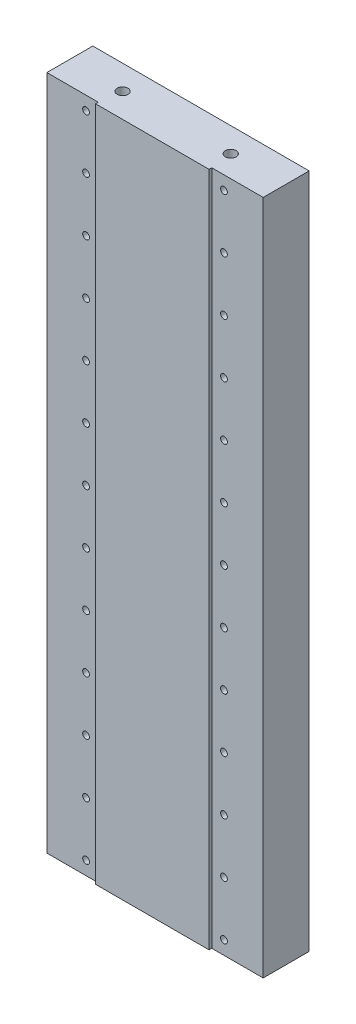
from build123d import *

# Parameters (mm, degrees)
CROQUIS1_W                         = 80
CROQUIS1_H                         = 250
SALIENTE_EXTRUIR1_DEPTH            = 18
CROQUIS2_W                         = 19
CROQUIS2_H                         = 250
CORTAR_EXTRUIR1_DEPTH              = 1
MATRIZL1_COUNT                     = 13
MATRIZL1_PITCH                     = 20
MATRIZL1_COUNT_DIR2                = 2
MATRIZL1_PITCH_DIR2                = 51
TALADROS_DE_ESPIGA_DE_4_0MM1_D     = 4
TALADROS_DE_ESPIGA_DE_4_0MM1_DEPTH = 12
TALADROS_DE_ESPIGA_DE_4_0MM1_TIP   = 1.201721238
TALADRO_ROSCADO_M41_D              = 3.3
TALADRO_ROSCADO_M41_DEPTH          = 11.5
TALADRO_ROSCADO_M41_TIP            = 0.991420021


with BuildPart() as part:
    # Croquis1 → Saliente-Extruir1 (new body)
    with BuildSketch(Plane.XY):
        with Locations((40, 125)):
            Rectangle(CROQUIS1_W, CROQUIS1_H)
    extrude(amount=SALIENTE_EXTRUIR1_DEPTH)

    # Croquis2 → Cortar-Extruir1 (cut)
    with BuildSketch(Plane.XY.offset(18)):
        with Locations((9.5, 125)):
            Rectangle(CROQUIS2_W, CROQUIS2_H)
        with Locations((70.5, 125)):
            Rectangle(CROQUIS2_W, CROQUIS2_H)
    extrude(amount=-CORTAR_EXTRUIR1_DEPTH, mode=Mode.SUBTRACT)

    # Croquis4 → Taladro roscado M31 (revolve, cut)
    with BuildSketch(Plane(origin=(14.5, 245, 17), x_dir=(0, -1, 0), z_dir=(1, 0, 0))):
        Polygon((0, 0), (0, 10.751075774), (1.25, 10), (1.25, 0), align=None)
    taladro_roscado_m31 = revolve(axis=Axis((14.5, 245, 23.35), (0, 0, -1)), mode=Mode.SUBTRACT)

    # MatrizL1: Taladro roscado M31 13 × 2
    with Locations(*[(j * MATRIZL1_PITCH_DIR2, -i * MATRIZL1_PITCH, 0) for i in range(MATRIZL1_COUNT) for j in range(MATRIZL1_COUNT_DIR2) if (i, j) != (0, 0)]):
        add(taladro_roscado_m31, mode=Mode.SUBTRACT)

    # Taladros de espiga de Ø4.0mm1
    with Locations(Plane(origin=(0, 250, 0), x_dir=(1, 0, 0), z_dir=(0, 1, 0))):
        with Locations((60, -9), (20, -9)):
            Hole(TALADROS_DE_ESPIGA_DE_4_0MM1_D / 2, depth=TALADROS_DE_ESPIGA_DE_4_0MM1_DEPTH)
            with Locations((0, 0, -(TALADROS_DE_ESPIGA_DE_4_0MM1_DEPTH + TALADROS_DE_ESPIGA_DE_4_0MM1_TIP / 2))):  # 118° drill point
                Cone(0, TALADROS_DE_ESPIGA_DE_4_0MM1_D / 2, TALADROS_DE_ESPIGA_DE_4_0MM1_TIP, mode=Mode.SUBTRACT)

    # Taladro roscado M41
    with Locations(Plane(origin=(0, 0, 0), x_dir=(-1, 0, 0), z_dir=(0, 0, -1))):
        with Locations((-73.5, 196), (-6.5, 237), (-73.5, 237), (-6.5, 196)):
            Hole(TALADRO_ROSCADO_M41_D / 2, depth=TALADRO_ROSCADO_M41_DEPTH)
            with Locations((0, 0, -(TALADRO_ROSCADO_M41_DEPTH + TALADRO_ROSCADO_M41_TIP / 2))):  # 118° drill point
                Cone(0, TALADRO_ROSCADO_M41_D / 2, TALADRO_ROSCADO_M41_TIP, mode=Mode.SUBTRACT)


solid = part.part
